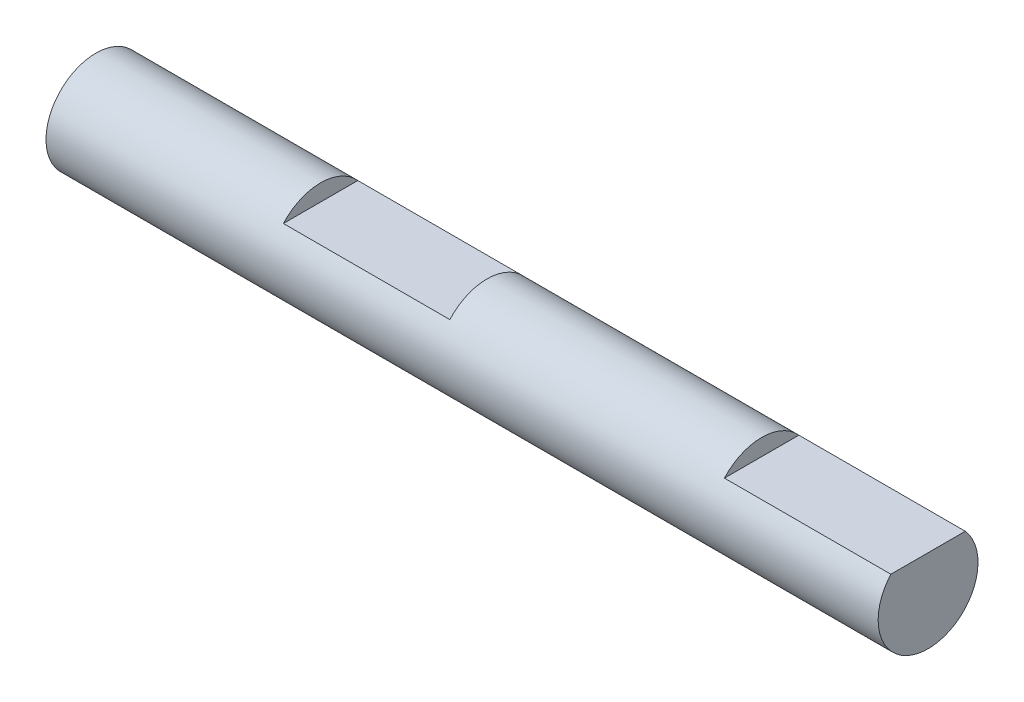
from build123d import *

# Parameters (mm, degrees)
SKIZZE1_W                            = 50
SKIZZE1_H                            = 3
SKIZZE2_W                            = 10
SKIZZE2_H                            = 2
SCHNITT_LINEAR_AUSTRAGEN1_DEPTH      = 4
SCHNITT_LINEAR_AUSTRAGEN1_DEPTH_BACK = 4


with BuildPart() as part:
    # Skizze1 → Rotation1 (revolve)
    with BuildSketch(Plane.XY):
        with Locations((25, 1.5)):
            Rectangle(SKIZZE1_W, SKIZZE1_H)
    revolve(axis=Axis((0, 0, 0), (1, 0, 0)))

    # Skizze2 → Schnitt-Linear austragen1 (cut, two sides)
    with BuildSketch(Plane.XY) as schnitt_linear_austragen1_sk:
        with Locations((18.5, 3)):
            Rectangle(SKIZZE2_W, SKIZZE2_H)
        with Locations((45, 3)):
            Rectangle(SKIZZE2_W, SKIZZE2_H)
    extrude(amount=SCHNITT_LINEAR_AUSTRAGEN1_DEPTH, mode=Mode.SUBTRACT)
    extrude(schnitt_linear_austragen1_sk.sketch, amount=-SCHNITT_LINEAR_AUSTRAGEN1_DEPTH_BACK, mode=Mode.SUBTRACT)


solid = part.part
